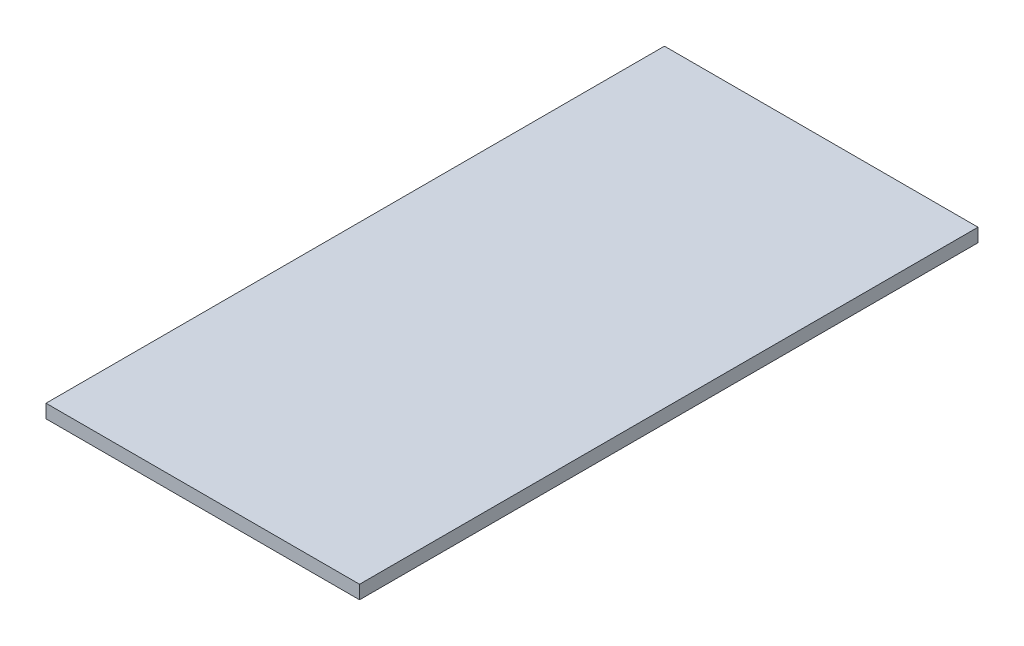
from build123d import *

# Parameters (mm, degrees)
SKETCH2_W           = 73.66
SKETCH2_H           = 145.288
BOSS_EXTRUDE1_DEPTH = 3.175


with BuildPart() as part:
    # Sketch2 → Boss-Extrude1 (new body)
    with BuildSketch(Plane(origin=(0, 0, 0), x_dir=(1, 0, 0), z_dir=(0, 1, 0))):
        Rectangle(SKETCH2_W, SKETCH2_H)
    extrude(amount=BOSS_EXTRUDE1_DEPTH)


solid = part.part
